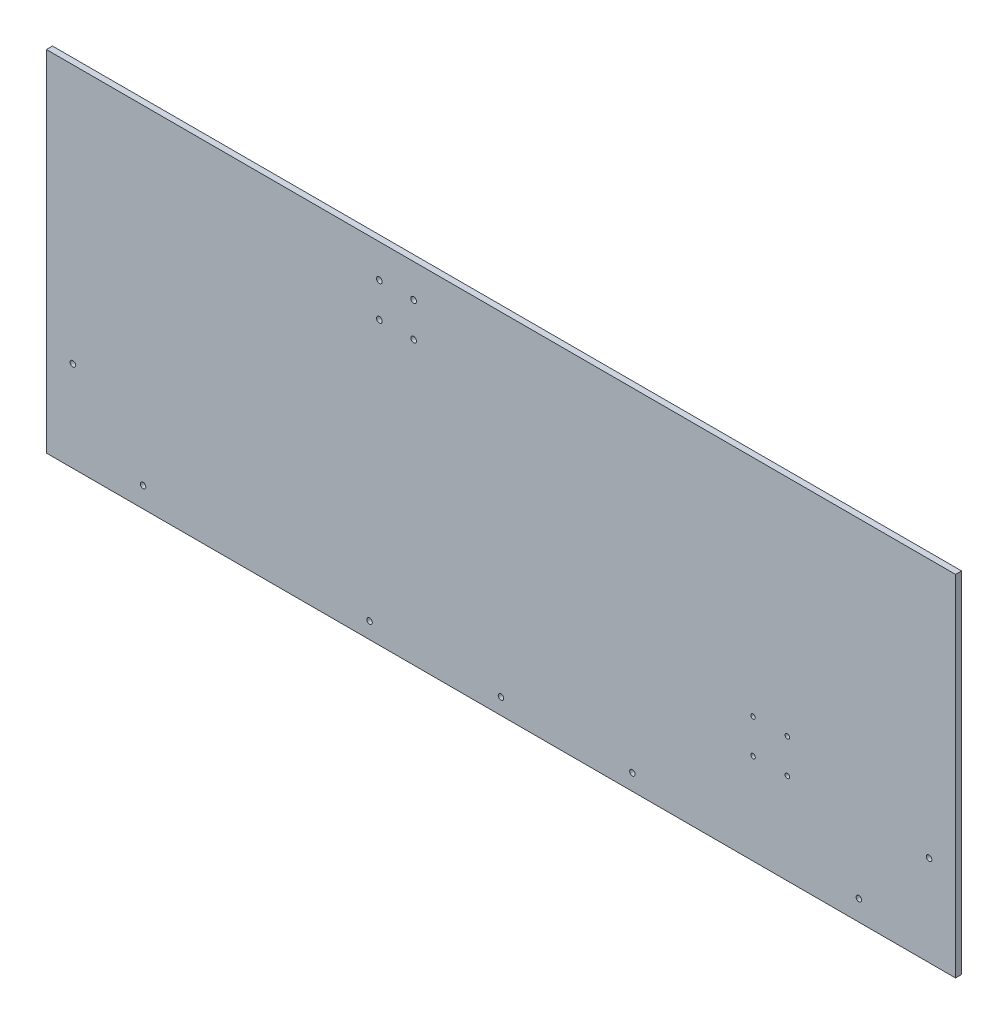
from build123d import *

# Parameters (mm, degrees)
SKETCH1_W                 = 714.375
SKETCH1_H                 = 274.6375
BOSS_EXTRUDE1_DEPTH       = 4.7625
CUT_EXTRUDE1_DEPTH        = 5.7625
CUT_EXTRUDE3_DEPTH        = 5.7625
CUT_EXTRUDE4_REACH        = 6.763
SKETCH5_R                 = 2.15265
BOSS_EXTRUDE2_START       = -692.15
SKETCH7_W                 = 4.7625
SKETCH7_H                 = 274.6375
BOSS_EXTRUDE2_DEPTH       = 669.925
F_8_CLEARANCE_HOLE1_D     = 4.3053
F_8_CLEARANCE_HOLE1_DEPTH = 74.422
F_8_CLEARANCE_HOLE1_TIP   = 1.293442612
F_8_CLEARANCE_HOLE2_D     = 4.3053
F_8_CLEARANCE_HOLE2_DEPTH = 74.422
F_8_CLEARANCE_HOLE2_TIP   = 1.293442612
F_8_CLEARANCE_HOLE3_D     = 4.4958
F_8_CLEARANCE_HOLE3_DEPTH = 74.422
F_8_CLEARANCE_HOLE3_TIP   = 1.350674586
SKETCH16_R                = 1.778
CUT_EXTRUDE5_DEPTH        = 4.7625


with BuildPart() as part:
    # Sketch1 → Boss-Extrude1 (new body)
    with BuildSketch(Plane.XY):
        Rectangle(SKETCH1_W, SKETCH1_H)
    extrude(amount=BOSS_EXTRUDE1_DEPTH)

    # Sketch2 → Cut-Extrude1 (cut, through all)
    with BuildSketch(Plane.XY.offset(4.7625)):
        with BuildLine():
            Line((12.285980323, -89.570459076), (10.351389114, -91.505050285))
            ThreePointArc((10.351389114, -91.505050285), (0, -88.10625), (-10.351389114, -91.505050285))
            Line((-10.351389114, -91.505050285), (-12.285980323, -89.570459076))
            ThreePointArc((-12.285980323, -89.570459076), (-15.998290924, -89.570459076), (-15.998290924, -93.282769677))
            Line((-15.998290924, -93.282769677), (-14.063699715, -95.217360886))
            ThreePointArc((-14.063699715, -95.217360886), (-17.4625, -105.56875), (-14.063699715, -115.920139114))
            Line((-14.063699715, -115.920139114), (-15.998290924, -117.854730323))
            ThreePointArc((-15.998290924, -117.854730323), (-15.998290924, -121.567040924), (-12.285980323, -121.567040924))
            Line((-12.285980323, -121.567040924), (-10.351389114, -119.632449715))
            ThreePointArc((-10.351389114, -119.632449715), (0, -123.03125), (10.351389114, -119.632449715))
            Line((10.351389114, -119.632449715), (12.285980323, -121.567040924))
            ThreePointArc((12.285980323, -121.567040924), (15.998290924, -121.567040924), (15.998290924, -117.854730323))
            Line((15.998290924, -117.854730323), (14.063699715, -115.920139114))
            ThreePointArc((14.063699715, -115.920139114), (17.4625, -105.56875), (14.063699715, -95.217360886))
            Line((14.063699715, -95.217360886), (15.998290924, -93.282769677))
            ThreePointArc((15.998290924, -93.282769677), (15.998290924, -89.570459076), (12.285980323, -89.570459076))
        make_face()
        with BuildLine():
            Line((-305.214019677, -89.570459076), (-307.148610886, -91.505050285))
            ThreePointArc((-307.148610886, -91.505050285), (-317.5, -88.10625), (-327.851389114, -91.505050285))
            Line((-327.851389114, -91.505050285), (-329.785980323, -89.570459076))
            ThreePointArc((-329.785980323, -89.570459076), (-333.498290924, -89.570459076), (-333.498290924, -93.282769677))
            Line((-333.498290924, -93.282769677), (-331.563699715, -95.217360886))
            ThreePointArc((-331.563699715, -95.217360886), (-334.9625, -105.56875), (-331.563699715, -115.920139114))
            Line((-331.563699715, -115.920139114), (-333.498290924, -117.854730323))
            ThreePointArc((-333.498290924, -117.854730323), (-333.498290924, -121.567040924), (-329.785980323, -121.567040924))
            Line((-329.785980323, -121.567040924), (-327.851389114, -119.632449715))
            ThreePointArc((-327.851389114, -119.632449715), (-317.5, -123.03125), (-307.148610886, -119.632449715))
            Line((-307.148610886, -119.632449715), (-305.214019677, -121.567040924))
            ThreePointArc((-305.214019677, -121.567040924), (-301.501709076, -121.567040924), (-301.501709076, -117.854730323))
            Line((-301.501709076, -117.854730323), (-303.436300285, -115.920139114))
            ThreePointArc((-303.436300285, -115.920139114), (-300.0375, -105.56875), (-303.436300285, -95.217360886))
            Line((-303.436300285, -95.217360886), (-301.501709076, -93.282769677))
            ThreePointArc((-301.501709076, -93.282769677), (-301.501709076, -89.570459076), (-305.214019677, -89.570459076))
        make_face()
        with BuildLine():
            Line((329.785980323, -89.570459076), (327.851389114, -91.505050285))
            ThreePointArc((327.851389114, -91.505050285), (317.5, -88.10625), (307.148610886, -91.505050285))
            Line((307.148610886, -91.505050285), (305.214019677, -89.570459076))
            ThreePointArc((305.214019677, -89.570459076), (301.501709076, -89.570459076), (301.501709076, -93.282769677))
            Line((301.501709076, -93.282769677), (303.436300285, -95.217360886))
            ThreePointArc((303.436300285, -95.217360886), (300.0375, -105.56875), (303.436300285, -115.920139114))
            Line((303.436300285, -115.920139114), (301.501709076, -117.854730323))
            ThreePointArc((301.501709076, -117.854730323), (301.501709076, -121.567040924), (305.214019677, -121.567040924))
            Line((305.214019677, -121.567040924), (307.148610886, -119.632449715))
            ThreePointArc((307.148610886, -119.632449715), (317.5, -123.03125), (327.851389114, -119.632449715))
            Line((327.851389114, -119.632449715), (329.785980323, -121.567040924))
            ThreePointArc((329.785980323, -121.567040924), (333.498290924, -121.567040924), (333.498290924, -117.854730323))
            Line((333.498290924, -117.854730323), (331.563699715, -115.920139114))
            ThreePointArc((331.563699715, -115.920139114), (334.9625, -105.56875), (331.563699715, -95.217360886))
            Line((331.563699715, -95.217360886), (333.498290924, -93.282769677))
            ThreePointArc((333.498290924, -93.282769677), (333.498290924, -89.570459076), (329.785980323, -89.570459076))
        make_face()
    extrude(amount=-CUT_EXTRUDE1_DEPTH, mode=Mode.SUBTRACT)

    # Sketch4 → Cut-Extrude3 (cut, through all)
    with BuildSketch(Plane.XY.offset(4.7625)):
        with BuildLine():
            Line((277.1521, 88.42375), (277.1521, 97.31375))
            ThreePointArc((277.1521, 97.31375), (279.4, 99.56165), (281.6479, 97.31375))
            Line((281.6479, 97.31375), (281.6479, 88.42375))
            ThreePointArc((281.6479, 88.42375), (279.4, 86.17585), (277.1521, 88.42375))
        make_face()
        with BuildLine():
            Line((-277.1521, 88.42375), (-277.1521, 97.31375))
            ThreePointArc((-277.1521, 97.31375), (-279.4, 99.56165), (-281.6479, 97.31375))
            Line((-281.6479, 97.31375), (-281.6479, 88.42375))
            ThreePointArc((-281.6479, 88.42375), (-279.4, 86.17585), (-277.1521, 88.42375))
        make_face()
    extrude(amount=-CUT_EXTRUDE3_DEPTH, mode=Mode.SUBTRACT)

    # Sketch5 → Cut-Extrude4 (cut, up to next)
    with BuildSketch(Plane.XY.offset(4.7625), mode=Mode.PRIVATE) as cut_extrude4_sk1:
        with Locations((-127, -105.56875)):
            Circle(SKETCH5_R)
    cut_extrude4_tool1 = extrude(cut_extrude4_sk1.sketch, amount=-CUT_EXTRUDE4_REACH, mode=Mode.PRIVATE) & part.part
    add(cut_extrude4_tool1.solids().sort_by_distance((-127, -105.56875, 4.7625))[0], mode=Mode.SUBTRACT)
    # Sketch5 → Cut-Extrude4 (cut, up to next)
    with BuildSketch(Plane.XY.offset(4.7625), mode=Mode.PRIVATE) as cut_extrude4_sk2:
        with Locations((-215.9, -105.56875)):
            Circle(SKETCH5_R)
    cut_extrude4_tool2 = extrude(cut_extrude4_sk2.sketch, amount=-CUT_EXTRUDE4_REACH, mode=Mode.PRIVATE) & part.part
    add(cut_extrude4_tool2.solids().sort_by_distance((-215.9, -105.56875, 4.7625))[0], mode=Mode.SUBTRACT)
    # Sketch5 → Cut-Extrude4 (cut, up to next)
    with BuildSketch(Plane.XY.offset(4.7625), mode=Mode.PRIVATE) as cut_extrude4_sk3:
        with Locations((215.9, -105.56875)):
            Circle(SKETCH5_R)
    cut_extrude4_tool3 = extrude(cut_extrude4_sk3.sketch, amount=-CUT_EXTRUDE4_REACH, mode=Mode.PRIVATE) & part.part
    add(cut_extrude4_tool3.solids().sort_by_distance((215.9, -105.56875, 4.7625))[0], mode=Mode.SUBTRACT)
    # Sketch5 → Cut-Extrude4 (cut, up to next)
    with BuildSketch(Plane.XY.offset(4.7625), mode=Mode.PRIVATE) as cut_extrude4_sk4:
        with Locations((127, -105.56875)):
            Circle(SKETCH5_R)
    cut_extrude4_tool4 = extrude(cut_extrude4_sk4.sketch, amount=-CUT_EXTRUDE4_REACH, mode=Mode.PRIVATE) & part.part
    add(cut_extrude4_tool4.solids().sort_by_distance((127, -105.56875, 4.7625))[0], mode=Mode.SUBTRACT)

    # Sketch7 → Boss-Extrude2 (add)
    with BuildSketch(Plane(origin=(357.1875, 0, 0), x_dir=(0, 0, -1), z_dir=(1, 0, 0)).offset(BOSS_EXTRUDE2_START)):
        with Locations((-2.38125, 0)):
            Rectangle(SKETCH7_W, SKETCH7_H)
    extrude(amount=BOSS_EXTRUDE2_DEPTH)

    # #8 Clearance Hole1
    with Locations(Plane.XY.offset(4.7625)):
        with Locations((-336.41538, -66.13271), (-281.23896, -121.30913), (281.23896, -121.30913), (336.41538, -66.13271)):
            Hole(F_8_CLEARANCE_HOLE1_D / 2, depth=F_8_CLEARANCE_HOLE1_DEPTH)
            with Locations((0, 0, -(F_8_CLEARANCE_HOLE1_DEPTH + F_8_CLEARANCE_HOLE1_TIP / 2))):  # 118° drill point
                Cone(0, F_8_CLEARANCE_HOLE1_D / 2, F_8_CLEARANCE_HOLE1_TIP, mode=Mode.SUBTRACT)

    # #8 Clearance Hole2
    with Locations(Plane.XY.offset(4.7625)):
        with Locations((-103.251, -124.61875), (0, -124.61875), (103.251, -124.61875)):
            Hole(F_8_CLEARANCE_HOLE2_D / 2, depth=F_8_CLEARANCE_HOLE2_DEPTH)
            with Locations((0, 0, -(F_8_CLEARANCE_HOLE2_DEPTH + F_8_CLEARANCE_HOLE2_TIP / 2))):  # 118° drill point
                Cone(0, F_8_CLEARANCE_HOLE2_D / 2, F_8_CLEARANCE_HOLE2_TIP, mode=Mode.SUBTRACT)

    # #8 Clearance Hole3
    with Locations(Plane.XY.offset(4.7625)):
        with Locations((-95.5675, 111.15675), (-68.6435, 111.15675), (-95.5675, 84.23275), (-68.6435, 84.23275)):
            Hole(F_8_CLEARANCE_HOLE3_D / 2, depth=F_8_CLEARANCE_HOLE3_DEPTH)
            with Locations((0, 0, -(F_8_CLEARANCE_HOLE3_DEPTH + F_8_CLEARANCE_HOLE3_TIP / 2))):  # 118° drill point
                Cone(0, F_8_CLEARANCE_HOLE3_D / 2, F_8_CLEARANCE_HOLE3_TIP, mode=Mode.SUBTRACT)

    # Sketch16 → Cut-Extrude5 (cut)
    with BuildSketch(Plane.XY.offset(4.7625)):
        with Locations((198.048115818, -38.948865818)):
            Circle(SKETCH16_R)
        with Locations((224.988884182, -38.948865818)):
            Circle(SKETCH16_R)
        with Locations((224.988884182, -65.889634182)):
            Circle(SKETCH16_R)
        with Locations((198.048115818, -65.889634182)):
            Circle(SKETCH16_R)
    extrude(amount=-CUT_EXTRUDE5_DEPTH, mode=Mode.SUBTRACT)


solid = part.part
